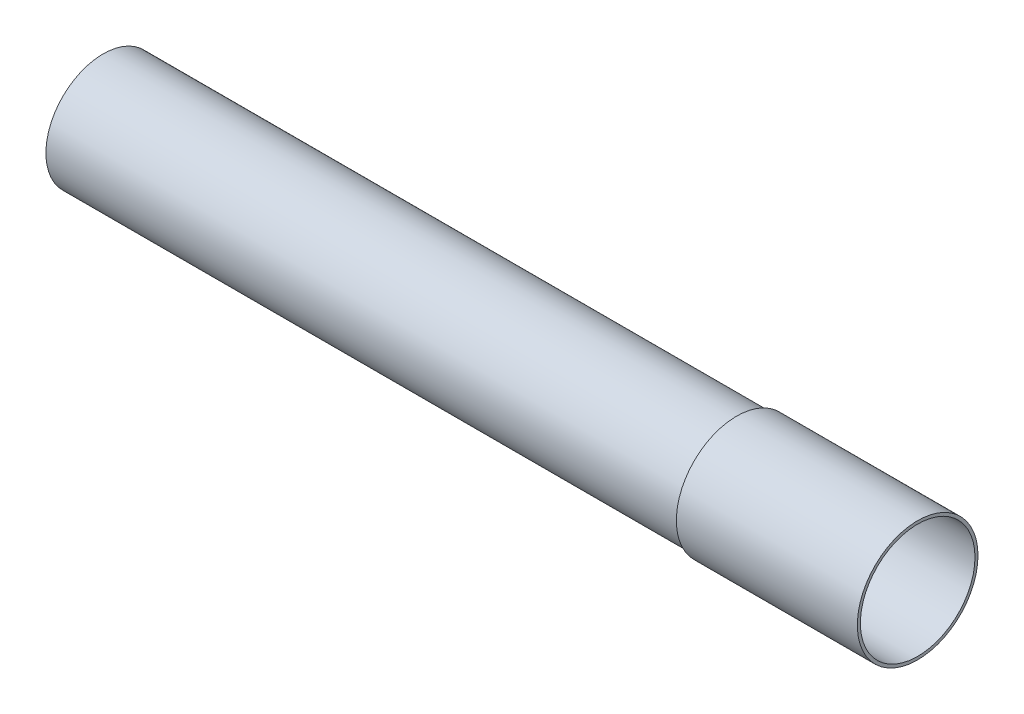
from build123d import *

# Parameters (mm, degrees)
SKETCH1_R           = 19
SKETCH1_R_2         = 17
BOSS_EXTRUDE1_DEPTH = 240
SKETCH2_R           = 20
SKETCH2_R_2         = 19
BOSS_EXTRUDE2_DEPTH = 30


with BuildPart() as part:
    # Sketch1 → Boss-Extrude1 (new body)
    with BuildSketch(Plane(origin=(0, 0, 0), x_dir=(0, 0, -1), z_dir=(1, 0, 0))):
        Circle(SKETCH1_R)
        Circle(SKETCH1_R_2, mode=Mode.SUBTRACT)
    extrude(amount=BOSS_EXTRUDE1_DEPTH)

    # Sketch2 → Boss-Extrude2 (add, symmetric)
    with BuildSketch(Plane(origin=(240, 0, 0), x_dir=(0, 0, -1), z_dir=(1, 0, 0))):
        Circle(SKETCH2_R)
        Circle(SKETCH2_R_2, mode=Mode.SUBTRACT)
    extrude(amount=BOSS_EXTRUDE2_DEPTH, both=True)


solid = part.part
